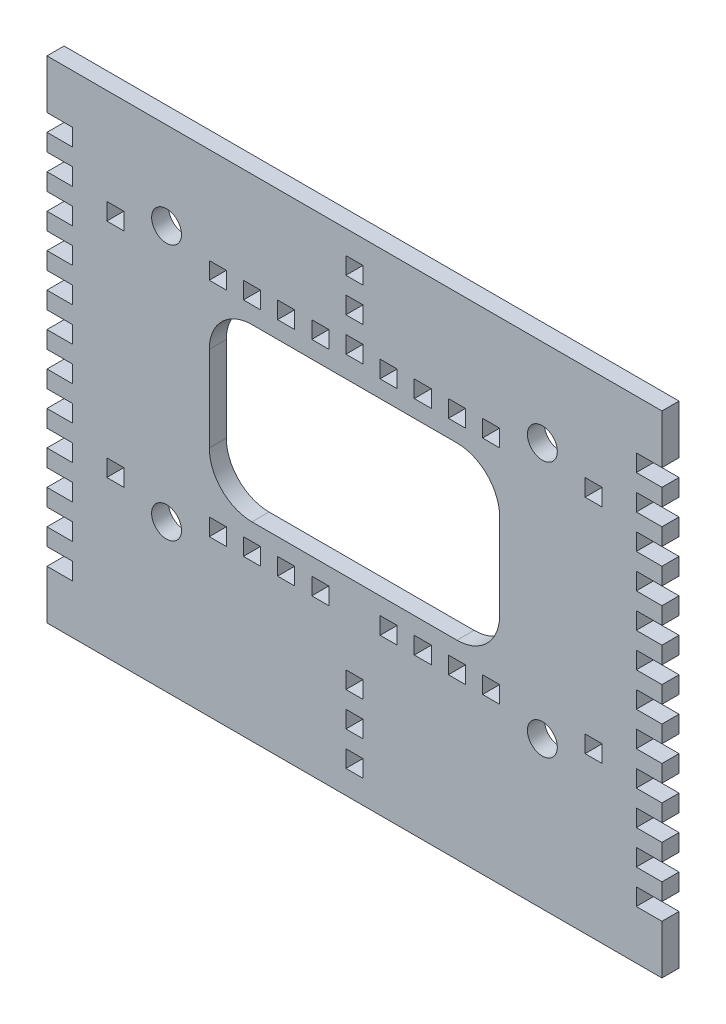
from build123d import *

# Parameters (mm, degrees)
SKETCH1_W           = 144
SKETCH1_H           = 115
SKETCH1_R           = 3.5
SKETCH1_W_2         = 4
SKETCH1_H_2         = 4
BOSS_EXTRUDE1_DEPTH = 4
SKETCH2_W           = 6
SKETCH2_H           = 4
CUT_EXTRUDE1_DEPTH  = 4
SKETCH4_W           = 4
SKETCH4_H           = 4
CUT_EXTRUDE2_DEPTH  = 10


with BuildPart() as part:
    # Sketch1 → Boss-Extrude1 (new body)
    with BuildSketch(Plane.XY):
        Rectangle(SKETCH1_W, SKETCH1_H)
        with Locations((-44, 37)):
            Circle(SKETCH1_R, mode=Mode.SUBTRACT)
        with Locations((44, 37)):
            Circle(SKETCH1_R, mode=Mode.SUBTRACT)
        with Locations((44, -23)):
            Circle(SKETCH1_R, mode=Mode.SUBTRACT)
        with Locations((-44, -23)):
            Circle(SKETCH1_R, mode=Mode.SUBTRACT)
        with Locations((0, 42)):
            Rectangle(SKETCH1_W_2, SKETCH1_H_2, mode=Mode.SUBTRACT)
        with BuildLine():
            Line((-24, 27), (24, 27))
            ThreePointArc((24, 27), (31.071067812, 24.071067812), (34, 17))
            Line((34, 17), (34, -3))
            ThreePointArc((34, -3), (31.071067812, -10.071067812), (24, -13))
            Line((24, -13), (-24, -13))
            ThreePointArc((-24, -13), (-31.071067812, -10.071067812), (-34, -3))
            Line((-34, -3), (-34, 17))
            ThreePointArc((-34, 17), (-31.071067812, 24.071067812), (-24, 27))
        make_face(mode=Mode.SUBTRACT)
        with Locations((0, 50)):
            Rectangle(SKETCH1_W_2, SKETCH1_H_2, mode=Mode.SUBTRACT)
        with Locations((0, 34)):
            Rectangle(SKETCH1_W_2, SKETCH1_H_2, mode=Mode.SUBTRACT)
        with Locations((0, -34)):
            Rectangle(SKETCH1_W_2, SKETCH1_H_2, mode=Mode.SUBTRACT)
        with Locations((0, -42)):
            Rectangle(SKETCH1_W_2, SKETCH1_H_2, mode=Mode.SUBTRACT)
        with Locations((0, -50)):
            Rectangle(SKETCH1_W_2, SKETCH1_H_2, mode=Mode.SUBTRACT)
    extrude(amount=BOSS_EXTRUDE1_DEPTH)

    # Sketch2 → Cut-Extrude1 (cut)
    with BuildSketch(Plane.XY.offset(4)):
        with Locations((-69, 12)):
            Rectangle(SKETCH2_W, SKETCH2_H)
        with Locations((-69, 4)):
            Rectangle(SKETCH2_W, SKETCH2_H)
        with Locations((-69, 20)):
            Rectangle(SKETCH2_W, SKETCH2_H)
        with Locations((-69, 28)):
            Rectangle(SKETCH2_W, SKETCH2_H)
        with Locations((-69, 36)):
            Rectangle(SKETCH2_W, SKETCH2_H)
        with Locations((-69, 44)):
            Rectangle(SKETCH2_W, SKETCH2_H)
        with Locations((69, 44)):
            Rectangle(SKETCH2_W, SKETCH2_H)
        with Locations((69, 36)):
            Rectangle(SKETCH2_W, SKETCH2_H)
        with Locations((69, 28)):
            Rectangle(SKETCH2_W, SKETCH2_H)
        with Locations((69, 20)):
            Rectangle(SKETCH2_W, SKETCH2_H)
        with Locations((69, 4)):
            Rectangle(SKETCH2_W, SKETCH2_H)
        with Locations((69, 12)):
            Rectangle(SKETCH2_W, SKETCH2_H)
        with Locations((69, -12)):
            Rectangle(SKETCH2_W, SKETCH2_H)
        with Locations((69, -4)):
            Rectangle(SKETCH2_W, SKETCH2_H)
        with Locations((69, -20)):
            Rectangle(SKETCH2_W, SKETCH2_H)
        with Locations((69, -28)):
            Rectangle(SKETCH2_W, SKETCH2_H)
        with Locations((69, -36)):
            Rectangle(SKETCH2_W, SKETCH2_H)
        with Locations((69, -44)):
            Rectangle(SKETCH2_W, SKETCH2_H)
        with Locations((-69, -44)):
            Rectangle(SKETCH2_W, SKETCH2_H)
        with Locations((-69, -36)):
            Rectangle(SKETCH2_W, SKETCH2_H)
        with Locations((-69, -28)):
            Rectangle(SKETCH2_W, SKETCH2_H)
        with Locations((-69, -20)):
            Rectangle(SKETCH2_W, SKETCH2_H)
        with Locations((-69, -4)):
            Rectangle(SKETCH2_W, SKETCH2_H)
        with Locations((-69, -12)):
            Rectangle(SKETCH2_W, SKETCH2_H)
    extrude(amount=-CUT_EXTRUDE1_DEPTH, mode=Mode.SUBTRACT)

    # Sketch4 → Cut-Extrude2 (cut)
    with BuildSketch(Plane.XY.offset(4)):
        with Locations((8, -19)):
            Rectangle(SKETCH4_W, SKETCH4_H)
        with Locations((16, -19)):
            Rectangle(SKETCH4_W, SKETCH4_H)
        with Locations((24, -19)):
            Rectangle(SKETCH4_W, SKETCH4_H)
        with Locations((32, -19)):
            Rectangle(SKETCH4_W, SKETCH4_H)
        with Locations((56, -19)):
            Rectangle(SKETCH4_W, SKETCH4_H)
        with Locations((-56, -19)):
            Rectangle(SKETCH4_W, SKETCH4_H)
        with Locations((-32, -19)):
            Rectangle(SKETCH4_W, SKETCH4_H)
        with Locations((-24, -19)):
            Rectangle(SKETCH4_W, SKETCH4_H)
        with Locations((-16, -19)):
            Rectangle(SKETCH4_W, SKETCH4_H)
        with Locations((-8, -19)):
            Rectangle(SKETCH4_W, SKETCH4_H)
        with Locations((8, 33)):
            Rectangle(SKETCH4_W, SKETCH4_H)
        with Locations((16, 33)):
            Rectangle(SKETCH4_W, SKETCH4_H)
        with Locations((24, 33)):
            Rectangle(SKETCH4_W, SKETCH4_H)
        with Locations((32, 33)):
            Rectangle(SKETCH4_W, SKETCH4_H)
        with Locations((-56, 33)):
            Rectangle(SKETCH4_W, SKETCH4_H)
        with Locations((-32, 33)):
            Rectangle(SKETCH4_W, SKETCH4_H)
        with Locations((56, 33)):
            Rectangle(SKETCH4_W, SKETCH4_H)
        with Locations((-24, 33)):
            Rectangle(SKETCH4_W, SKETCH4_H)
        with Locations((-16, 33)):
            Rectangle(SKETCH4_W, SKETCH4_H)
        with Locations((-8, 33)):
            Rectangle(SKETCH4_W, SKETCH4_H)
    extrude(amount=-CUT_EXTRUDE2_DEPTH, mode=Mode.SUBTRACT)


solid = part.part
